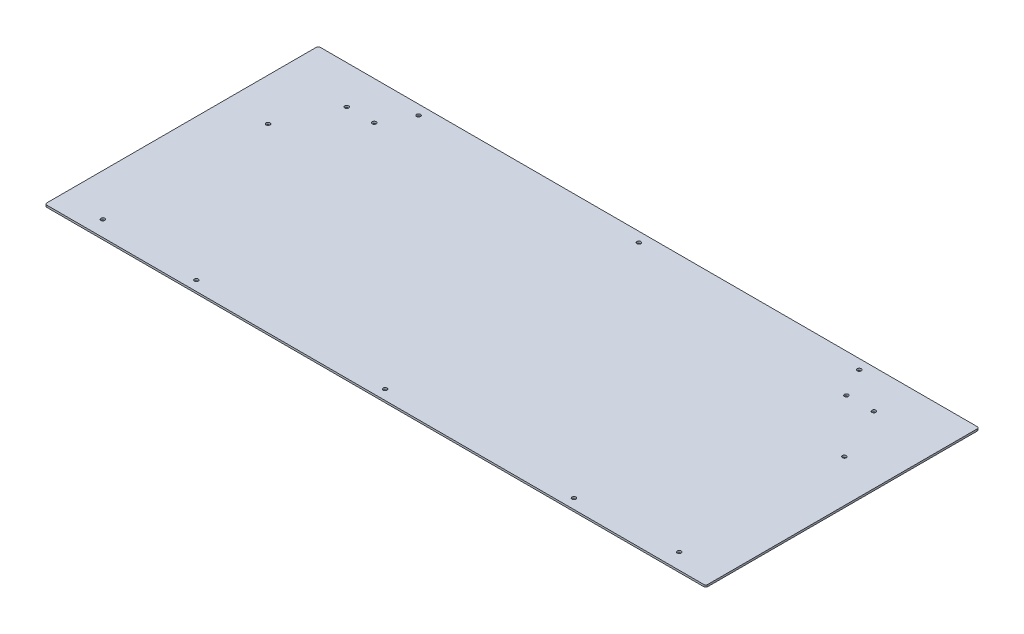
from build123d import *

# Parameters (mm, degrees)
SKETCH1_W                   = 1066.8
SKETCH1_H                   = 441.325
BOSS_EXTRUDE1_DEPTH         = 3.175
F_1_4_0_25_DIAMETER_HOLE1_D = 6.35
FILLET2_R                   = 3.175


with BuildPart() as part:
    # Sketch1 → Boss-Extrude1 (new body)
    with BuildSketch(Plane(origin=(0, 0, 0), x_dir=(1, 0, 0), z_dir=(0, 1, 0))):
        with Locations((533.4, 220.6625)):
            Rectangle(SKETCH1_W, SKETCH1_H)
    extrude(amount=BOSS_EXTRUDE1_DEPTH)

    # 1/4 (0.25) Diameter Hole1 (through all)
    with Locations(Plane(origin=(0, 3.175, 0), x_dir=(1, 0, 0), z_dir=(0, 1, 0))):
        with Locations((228.6, 15.875), (533.4, 15.875), (838.2, 15.875), (889, 425.45), (533.4, 425.45), (177.8, 425.45), (68.2625, 25.4), (68.2625, 292.1), (998.5375, 25.4), (998.5375, 292.1), (958.85, 379.3744), (914.4, 379.3744), (107.95, 379.3744), (152.4, 379.3744)):
            Hole(F_1_4_0_25_DIAMETER_HOLE1_D / 2)

    # Fillet2
    fillet2_edges = [part.edges().sort_by_distance(p)[0] for p in [
        (0, 1.5875, -441.325),
        (1066.8, 1.5875, -441.325),
        (1066.8, 1.5875, 0),
        (0, 1.5875, 0),
    ]]
    fillet(fillet2_edges, radius=FILLET2_R)


solid = part.part
